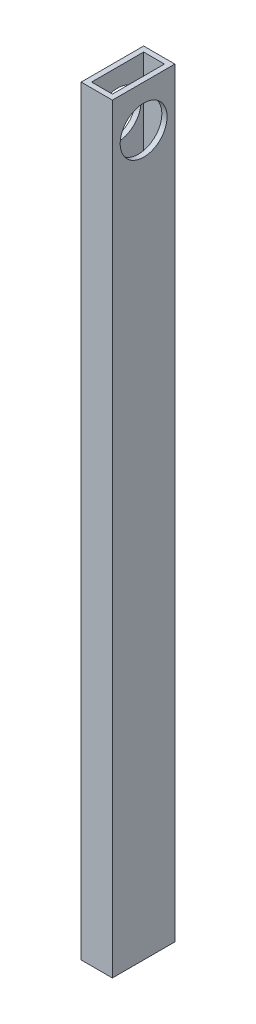
from build123d import *

# Parameters (mm, degrees)
SKETCH1_W           = 19.05
SKETCH1_H           = 38.1
SKETCH1_W_2         = 12.7
SKETCH1_H_2         = 31.75
EXTRUDE_THIN1_DEPTH = 463.55
SKETCH2_R           = 14.2875
CUT_EXTRUDE1_DEPTH  = 19.05


with BuildPart() as part:
    # Sketch1 → Extrude-Thin1 (new body)
    with BuildSketch(Plane(origin=(0, 0, 0), x_dir=(1, 0, 0), z_dir=(0, 1, 0))):
        with Locations((9.525, 19.05)):
            Rectangle(SKETCH1_W, SKETCH1_H)
        with Locations((9.525, 19.05)):
            Rectangle(SKETCH1_W_2, SKETCH1_H_2, mode=Mode.SUBTRACT)
    extrude(amount=EXTRUDE_THIN1_DEPTH)

    # Sketch2 → Cut-Extrude1 (cut)
    with BuildSketch(Plane(origin=(19.05, 0, 0), x_dir=(0, 0, -1), z_dir=(1, 0, 0))):
        with Locations((19.05, 438.15)):
            Circle(SKETCH2_R)
    extrude(amount=-CUT_EXTRUDE1_DEPTH, mode=Mode.SUBTRACT)


solid = part.part
